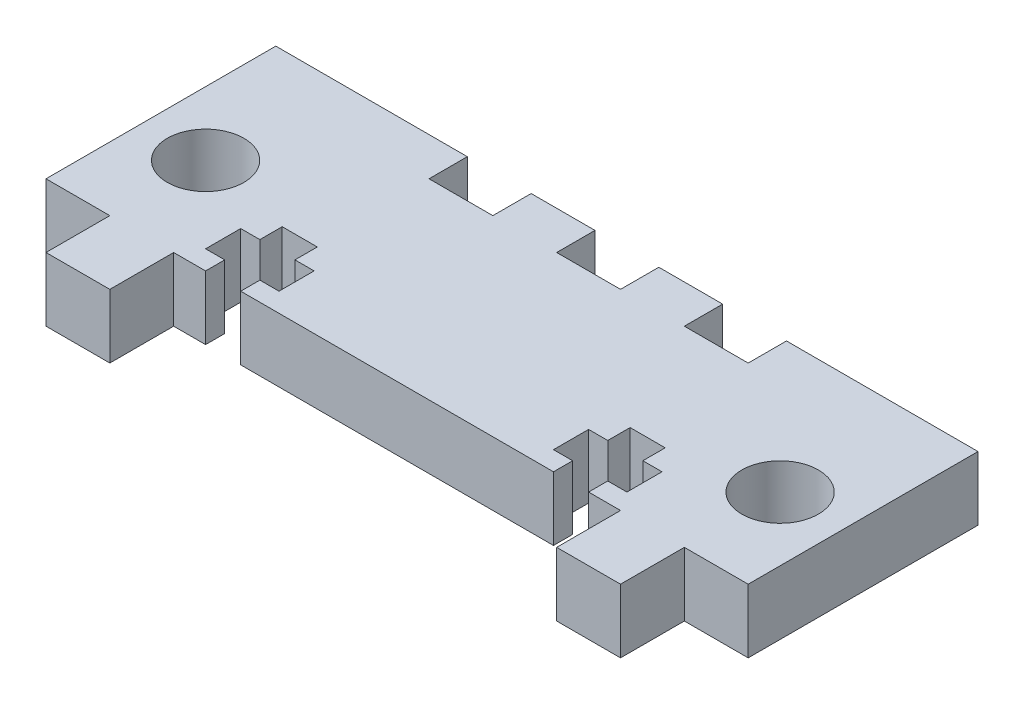
from build123d import *

# Parameters (mm, degrees)
ESQUISSE1_W             = 55
ESQUISSE1_H             = 23
BOSS_EXTRU_1_DEPTH      = 5
ESQUISSE2_R             = 3
ENL_V_MAT_EXTRU_1_DEPTH = 5
ENL_V_MAT_EXTRU_2_DEPTH = 10
ESQUISSE5_W             = 5
ESQUISSE5_H             = 5
ESQUISSE5_W_2           = 35
ENL_V_MAT_EXTRU_3_DEPTH = 6
ESQUISSE7_W             = 5
ESQUISSE7_H             = 3
ENL_V_MAT_EXTRU_4_DEPTH = 6


with BuildPart() as part:
    # Esquisse1 → Boss.-Extru.1 (new body)
    with BuildSketch(Plane(origin=(0, 0, 0), x_dir=(1, 0, 0), z_dir=(0, 1, 0))):
        with Locations((0, 4)):
            Rectangle(ESQUISSE1_W, ESQUISSE1_H)
    extrude(amount=BOSS_EXTRU_1_DEPTH)

    # Esquisse2 → Enlèv. mat.-Extru.1 (cut)
    with BuildSketch(Plane(origin=(0, 5, 0), x_dir=(1, 0, 0), z_dir=(0, 1, 0))):
        with Locations((-22.5, 5)):
            Circle(ESQUISSE2_R)
        with Locations((22.5, 5)):
            Circle(ESQUISSE2_R)
    extrude(amount=-ENL_V_MAT_EXTRU_1_DEPTH, mode=Mode.SUBTRACT)

    # Esquisse4 → Enlèv. mat.-Extru.2 (cut)
    with BuildSketch(Plane(origin=(0, 5, 0), x_dir=(1, 0, 0), z_dir=(0, 1, 0))):
        Polygon((-15, 3.5), (-15, 1.75), (-16.5, 1.75), (-16.5, -1), (-15, -1), (-15, -2.5), (-12.25, -2.5), (-12.25, -1), (-10.75, -1), (-10.75, 1.75), (-12.25, 1.75), (-12.25, 3.5), align=None)
        Polygon((12.25, 3.5), (15, 3.5), (15, 1.75), (16.5, 1.75), (16.5, -1), (15, -1), (15, -2.5), (12.25, -2.5), (12.25, -1), (10.75, -1), (10.75, 1.75), (12.25, 1.75), align=None)
    extrude(amount=-ENL_V_MAT_EXTRU_2_DEPTH, mode=Mode.SUBTRACT)

    # Esquisse5 → Enlèv. mat.-Extru.3 (cut, through all)
    with BuildSketch(Plane(origin=(0, 5, 0), x_dir=(1, 0, 0), z_dir=(0, 1, 0))):
        with Locations((-25, -5)):
            Rectangle(ESQUISSE5_W, ESQUISSE5_H)
        with Locations((0, -5)):
            Rectangle(ESQUISSE5_W_2, ESQUISSE5_H)
        with Locations((25, -5)):
            Rectangle(ESQUISSE5_W, ESQUISSE5_H)
    extrude(amount=-ENL_V_MAT_EXTRU_3_DEPTH, mode=Mode.SUBTRACT)

    # Esquisse7 → Enlèv. mat.-Extru.4 (cut, through all)
    with BuildSketch(Plane(origin=(0, 5, 0), x_dir=(1, 0, 0), z_dir=(0, 1, 0))):
        with Locations((0, 14)):
            Rectangle(ESQUISSE7_W, ESQUISSE7_H)
        with Locations((10, 14)):
            Rectangle(ESQUISSE7_W, ESQUISSE7_H)
        with Locations((-10, 14)):
            Rectangle(ESQUISSE7_W, ESQUISSE7_H)
    extrude(amount=-ENL_V_MAT_EXTRU_4_DEPTH, mode=Mode.SUBTRACT)


solid = part.part
